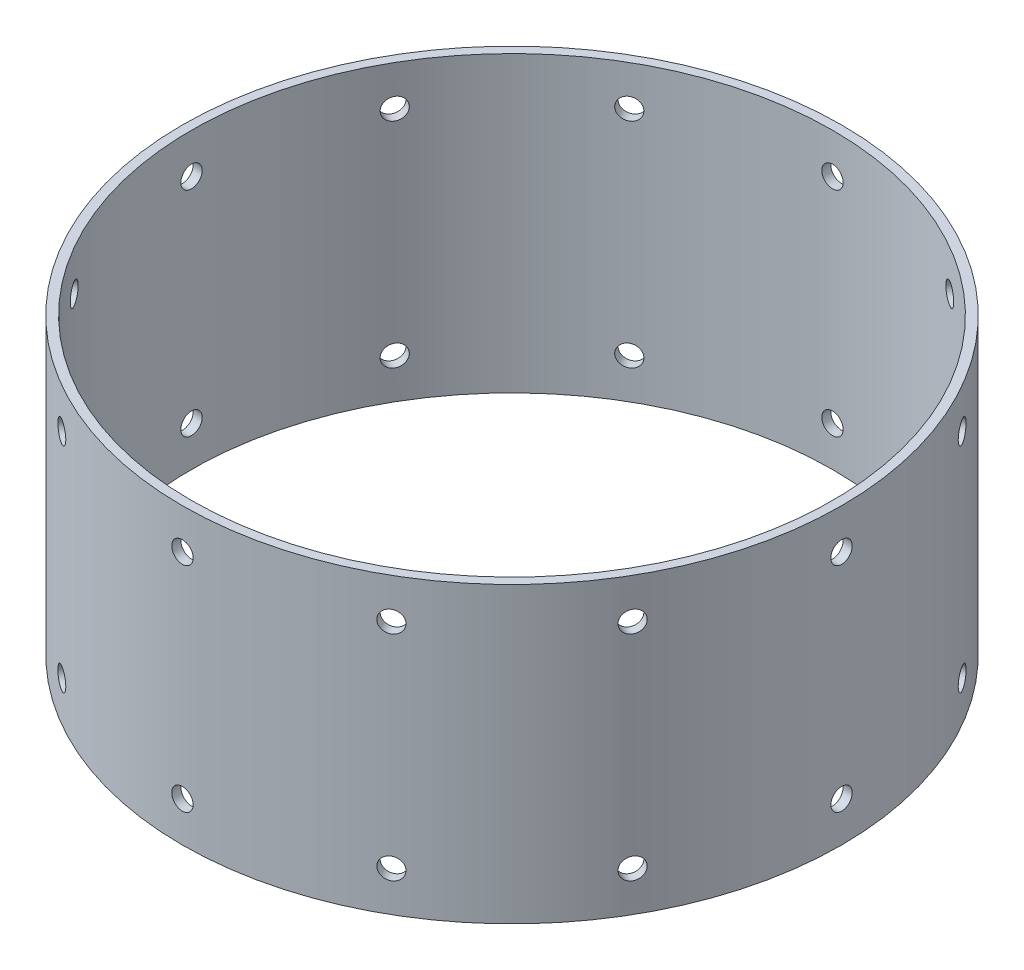
from build123d import *

# Parameters (mm, degrees)
SKETCH1_R           = 78.359
SKETCH1_R_2         = 76.2
BOSS_EXTRUDE1_DEPTH = 69.85
SKETCH2_R           = 2.54
CUT_EXTRUDE1_DEPTH  = 79.359
CIRPATTERN1_COUNT   = 12


with BuildPart() as part:
    # Sketch1 → Boss-Extrude1 (new body)
    with BuildSketch(Plane(origin=(0, 0, 0), x_dir=(1, 0, 0), z_dir=(0, 1, 0))):
        Circle(SKETCH1_R)
        Circle(SKETCH1_R_2, mode=Mode.SUBTRACT)
    extrude(amount=BOSS_EXTRUDE1_DEPTH)

    # Sketch2 → Cut-Extrude1 (cut, through all)
    with BuildSketch(Plane.XY):
        with Locations((0, 9.525)):
            Circle(SKETCH2_R)
        with Locations((0, 60.325)):
            Circle(SKETCH2_R)
    cut_extrude1 = extrude(amount=-CUT_EXTRUDE1_DEPTH, mode=Mode.SUBTRACT)

    # CirPattern1: Cut-Extrude1 ×12 about axis
    cirpattern1_axis = Axis((0, 0, 0), (0, 1, 0))
    for i in range(1, CIRPATTERN1_COUNT):
        add(cut_extrude1.rotate(cirpattern1_axis, i * 360 / CIRPATTERN1_COUNT), mode=Mode.SUBTRACT)


solid = part.part
